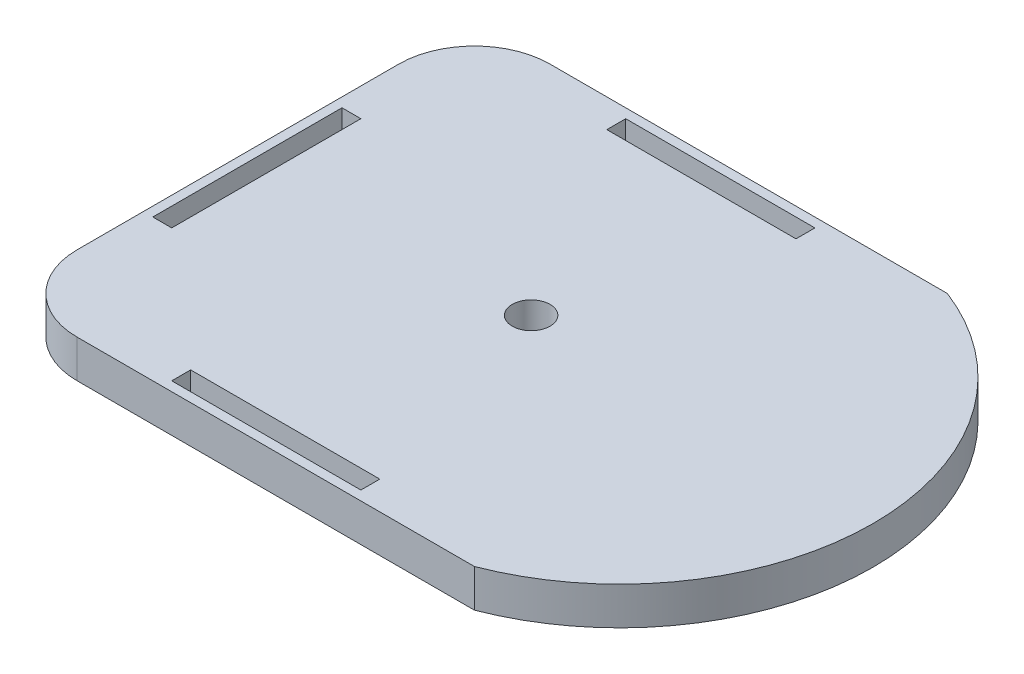
from build123d import *

# Parameters (mm, degrees)
Y_KSEKLIK_EKSTR_ZYON1_DEPTH = 20
IZIM2_W                     = 100
IZIM2_H                     = 10
IZIM2_W_2                   = 10
IZIM2_H_2                   = 100
KES_EKSTR_ZYON1_DEPTH       = 12.5
IZIM4_R                     = 10
KES_EKSTR_ZYON2_DEPTH       = 230.5


with BuildPart() as part:
    # Çizim1 → Yükseklik-Ekstrüzyon1 (new body)
    with BuildSketch(Plane(origin=(0, 0, 0), x_dir=(1, 0, 0), z_dir=(0, 1, 0))):
        with BuildLine():
            Line((-41.125316458, 193.880424863), (168.874683542, 193.880424863))
            ThreePointArc((168.874683542, 193.880424863), (254.603263886, 68.880424863), (168.874683542, -56.119575137))
            Line((168.874683542, -56.119575137), (-41.125316458, -56.119575137))
            ThreePointArc((-41.125316458, -56.119575137), (-69.409587706, -44.403846384), (-81.125316458, -16.119575137))
            Line((-81.125316458, -16.119575137), (-81.125316458, 153.880424863))
            ThreePointArc((-81.125316458, 153.880424863), (-69.409587706, 182.16469611), (-41.125316458, 193.880424863))
        make_face()
    extrude(amount=Y_KSEKLIK_EKSTR_ZYON1_DEPTH)

    # Çizim2 → Kes-Ekstrüzyon1 (cut)
    with BuildSketch(Plane(origin=(0, 20, 0), x_dir=(1, 0, 0), z_dir=(0, 1, 0))):
        with Locations((53.874683542, 183.880424863)):
            Rectangle(IZIM2_W, IZIM2_H)
        with Locations((-71.125316458, 68.880424863)):
            Rectangle(IZIM2_W_2, IZIM2_H_2)
        with Locations((53.874683542, -46.119575137)):
            Rectangle(IZIM2_W, IZIM2_H)
    extrude(amount=-KES_EKSTR_ZYON1_DEPTH, mode=Mode.SUBTRACT)

    # Çizim4 → Kes-Ekstrüzyon2 (cut)
    with BuildSketch(Plane(origin=(0, 20, 0), x_dir=(1, 0, 0), z_dir=(0, 1, 0))):
        with Locations((68.874683542, 73.880424863)):
            Circle(IZIM4_R)
    extrude(amount=-KES_EKSTR_ZYON2_DEPTH, mode=Mode.SUBTRACT)


solid = part.part
